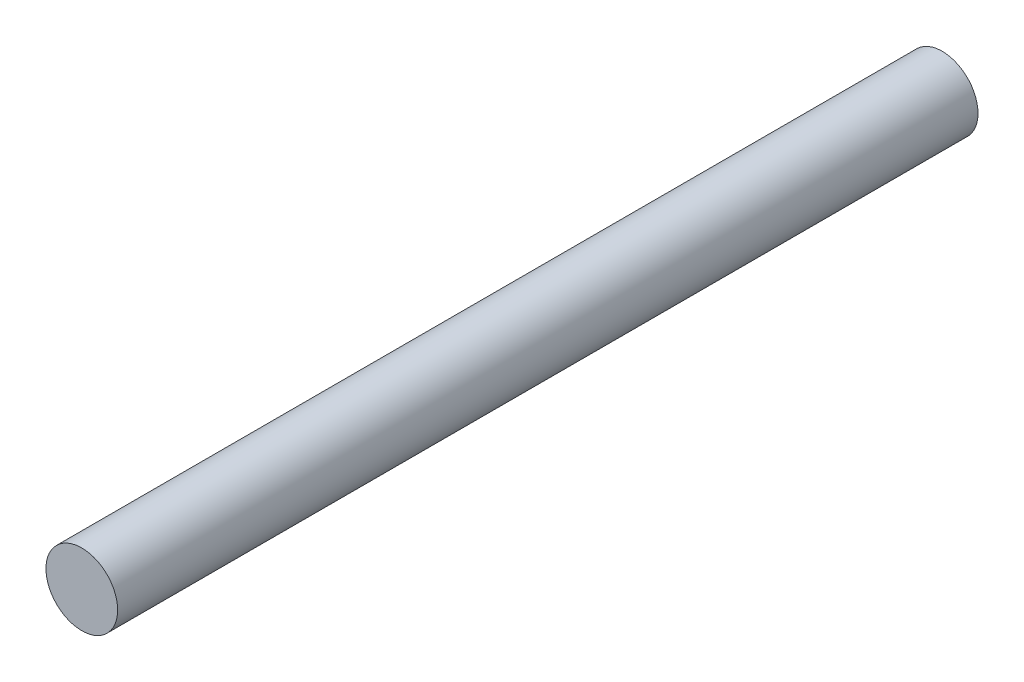
from build123d import *

# Parameters (mm, degrees)
SKETCH1_R           = 6.25
BOSS_EXTRUDE2_DEPTH = 150


with BuildPart() as part:
    # Sketch1 → Boss-Extrude2 (new body)
    with BuildSketch(Plane.XY):
        Circle(SKETCH1_R)
    extrude(amount=BOSS_EXTRUDE2_DEPTH)


solid = part.part
